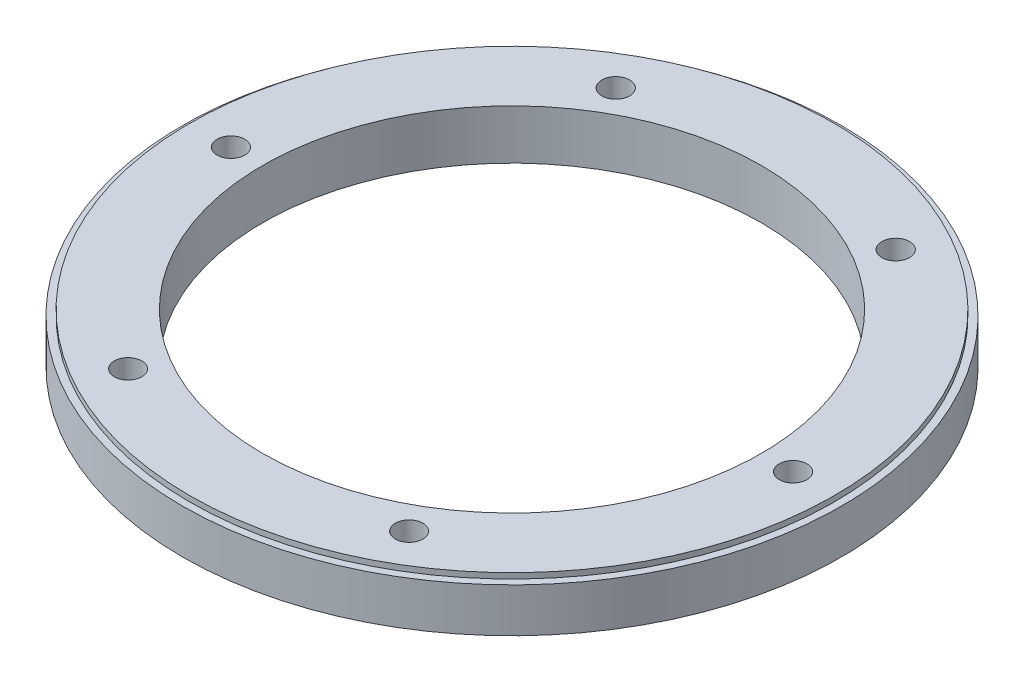
from build123d import *

# Parameters (mm, degrees)
SKETCH1_R               = 75.946
BOSS_EXTRUDE1_DEPTH     = 10.16
SKETCH7_R               = 74.295
BOSS_EXTRUDE2_DEPTH     = 1.27
SKETCH6_R               = 3.183478234
SKETCH6_R_2             = 3.2
SKETCH6_R_3             = 3.175
CUT_EXTRUDE5_DEPTH      = 2.27
CUT_EXTRUDE5_DEPTH_BACK = 11.16
SKETCH9_R               = 57.4675
CUT_EXTRUDE7_DEPTH      = 12.43


with BuildPart() as part:
    # Sketch1 → Boss-Extrude1 (new body)
    with BuildSketch(Plane(origin=(0, 0, 0), x_dir=(1, 0, 0), z_dir=(0, 1, 0))):
        Circle(SKETCH1_R)
    extrude(amount=BOSS_EXTRUDE1_DEPTH)

    # Sketch7 → Boss-Extrude2 (add)
    with BuildSketch(Plane(origin=(0, 10.16, 0), x_dir=(1, 0, 0), z_dir=(0, 1, 0))):
        Circle(SKETCH7_R)
    extrude(amount=BOSS_EXTRUDE2_DEPTH)

    # Sketch6 → Cut-Extrude5 (cut, two sides)
    with BuildSketch(Plane(origin=(0, 10.16, 0), x_dir=(1, 0, 0), z_dir=(0, 1, 0))) as cut_extrude5_sk:
        with Locations((-64.77, 0)):
            Circle(SKETCH6_R)
        with Locations((-32.260478415, 56.164173923)):
            Circle(SKETCH6_R_2)
        with Locations((-32.385, -56.092465403)):
            Circle(SKETCH6_R_3)
        with Locations((32.385, -56.092465403)):
            Circle(SKETCH6_R_3)
        with Locations((64.77, 0)):
            Circle(SKETCH6_R)
        with Locations((32.260478415, 56.164173923)):
            Circle(SKETCH6_R_2)
    extrude(amount=CUT_EXTRUDE5_DEPTH, mode=Mode.SUBTRACT)
    extrude(cut_extrude5_sk.sketch, amount=-CUT_EXTRUDE5_DEPTH_BACK, mode=Mode.SUBTRACT)

    # Sketch9 → Cut-Extrude7 (cut, through all)
    with BuildSketch(Plane(origin=(0, 11.43, 0), x_dir=(1, 0, 0), z_dir=(0, 1, 0))):
        Circle(SKETCH9_R)
    extrude(amount=-CUT_EXTRUDE7_DEPTH, mode=Mode.SUBTRACT)


solid = part.part
